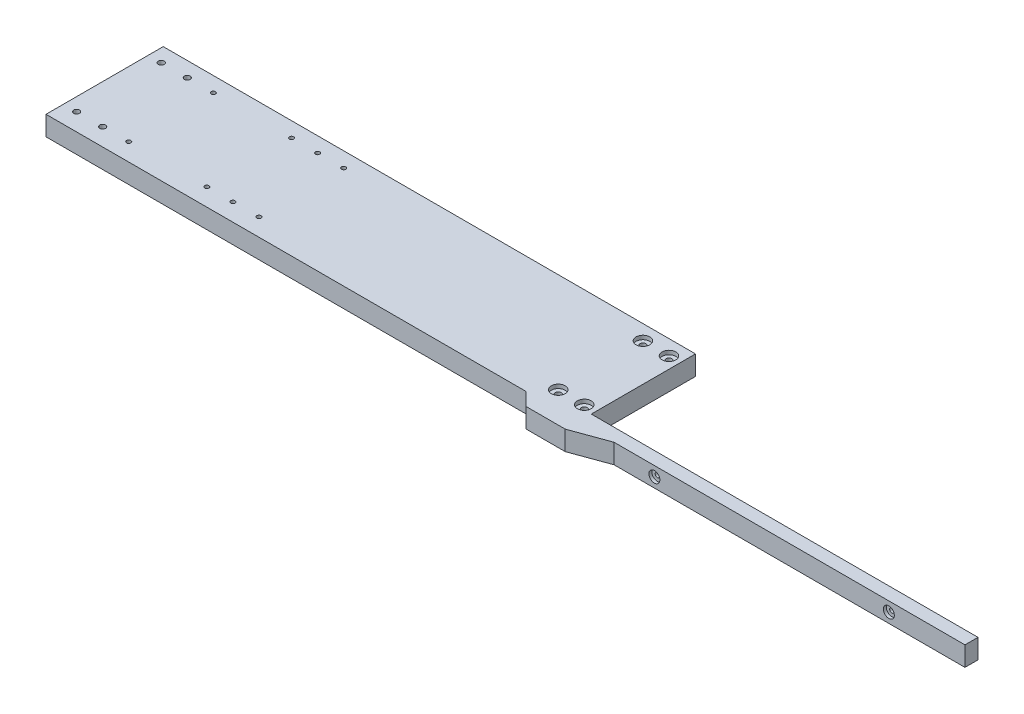
from build123d import *

# Parameters (mm, degrees)
SKETCH1_W                                        = 296.88
SKETCH1_H                                        = 15
BOSS_EXTRUDE1_DEPTH                              = 10
CBORE_FOR_M3_HEX_HEAD_MACHINE_SCREW1_D           = 3.4
CBORE_FOR_M3_HEX_HEAD_MACHINE_SCREW1_CBORE_D     = 8.4
CBORE_FOR_M3_HEX_HEAD_MACHINE_SCREW1_CBORE_DEPTH = 2.3
SKETCH5_W                                        = 40
SKETCH5_H                                        = 90
BOSS_EXTRUDE2_DEPTH                              = 15
CBORE_FOR_M4_HEX_HEAD_MACHINE_SCREW1_D           = 4.5
CBORE_FOR_M4_HEX_HEAD_MACHINE_SCREW1_CBORE_D     = 10.59
CBORE_FOR_M4_HEX_HEAD_MACHINE_SCREW1_CBORE_DEPTH = 3
BOSS_EXTRUDE3_DEPTH                              = 15
SKETCH13_W                                       = 368.635882897
SKETCH13_H                                       = 90
BOSS_EXTRUDE4_DEPTH                              = 15
M4_CLEARANCE_HOLE1_D                             = 4.5
M4X0_7_TAPPED_HOLE1_D                            = 3.3
M4X0_7_TAPPED_HOLE1_DEPTH                        = 10.1
M4X0_7_TAPPED_HOLE1_TIP                          = 0.991420021


with BuildPart() as part:
    # Sketch1 → Boss-Extrude1 (new body)
    with BuildSketch(Plane.XY):
        Rectangle(SKETCH1_W, SKETCH1_H)
    extrude(amount=-BOSS_EXTRUDE1_DEPTH)

    # CBORE for M3 Hex Head Machine Screw1 (through all)
    with Locations(Plane.XY):
        with Locations((-90, 0), (90, 0)):
            CounterBoreHole(CBORE_FOR_M3_HEX_HEAD_MACHINE_SCREW1_D / 2, CBORE_FOR_M3_HEX_HEAD_MACHINE_SCREW1_CBORE_D / 2, CBORE_FOR_M3_HEX_HEAD_MACHINE_SCREW1_CBORE_DEPTH)

    # Sketch5 → Boss-Extrude2 (add)
    with BuildSketch(Plane(origin=(0, 7.5, 0), x_dir=(1, 0, 0), z_dir=(0, 1, 0))):
        with Locations((-168.44, 45)):
            Rectangle(SKETCH5_W, SKETCH5_H)
    extrude(amount=-BOSS_EXTRUDE2_DEPTH)

    # CBORE for M4 Hex Head Machine Screw1 (through all)
    with Locations(Plane(origin=(0, 7.5, 0), x_dir=(1, 0, 0), z_dir=(0, 1, 0))):
        with Locations((-177.311326024, 13.5), (-157.311326024, 13.5), (-177.311326024, 78.5), (-157.311326024, 78.5)):
            CounterBoreHole(CBORE_FOR_M4_HEX_HEAD_MACHINE_SCREW1_D / 2, CBORE_FOR_M4_HEX_HEAD_MACHINE_SCREW1_CBORE_D / 2, CBORE_FOR_M4_HEX_HEAD_MACHINE_SCREW1_CBORE_DEPTH)

    # Sketch12 → Boss-Extrude3 (add)
    with BuildSketch(Plane(origin=(0, 7.5, 0), x_dir=(1, 0, 0), z_dir=(0, 1, 0))):
        Polygon((-188.44, 0), (-178.44, -10), (-148.44, -10), (-120.965225805, 0), align=None)
    extrude(amount=-BOSS_EXTRUDE3_DEPTH)

    # Sketch13 → Boss-Extrude4 (add)
    with BuildSketch(Plane(origin=(0, 7.5, 0), x_dir=(1, 0, 0), z_dir=(0, 1, 0))):
        with Locations((-372.757941448, 45)):
            Rectangle(SKETCH13_W, SKETCH13_H)
    extrude(amount=-BOSS_EXTRUDE4_DEPTH)

    # M4 Clearance Hole1 (through all)
    with Locations(Plane(origin=(0, 7.5, 0), x_dir=(1, 0, 0), z_dir=(0, 1, 0))):
        with Locations((-547.075882897, 78.5), (-527.075882897, 78.5), (-527.075882897, 13.5), (-547.075882897, 13.5)):
            Hole(M4_CLEARANCE_HOLE1_D / 2)

    # M4x0.7 Tapped Hole1
    with Locations(Plane(origin=(0, 7.5, 0), x_dir=(1, 0, 0), z_dir=(0, 1, 0))):
        with Locations((-507.075882897, 78.5), (-507.075882897, 13.5), (-447.075882897, 13.5), (-427.075882897, 13.5), (-407.075882897, 13.5), (-407.075882897, 78.5), (-427.075882897, 78.5), (-447.075882897, 78.5)):
            Hole(M4X0_7_TAPPED_HOLE1_D / 2, depth=M4X0_7_TAPPED_HOLE1_DEPTH)
            with Locations((0, 0, -(M4X0_7_TAPPED_HOLE1_DEPTH + M4X0_7_TAPPED_HOLE1_TIP / 2))):  # 118° drill point
                Cone(0, M4X0_7_TAPPED_HOLE1_D / 2, M4X0_7_TAPPED_HOLE1_TIP, mode=Mode.SUBTRACT)


solid = part.part
